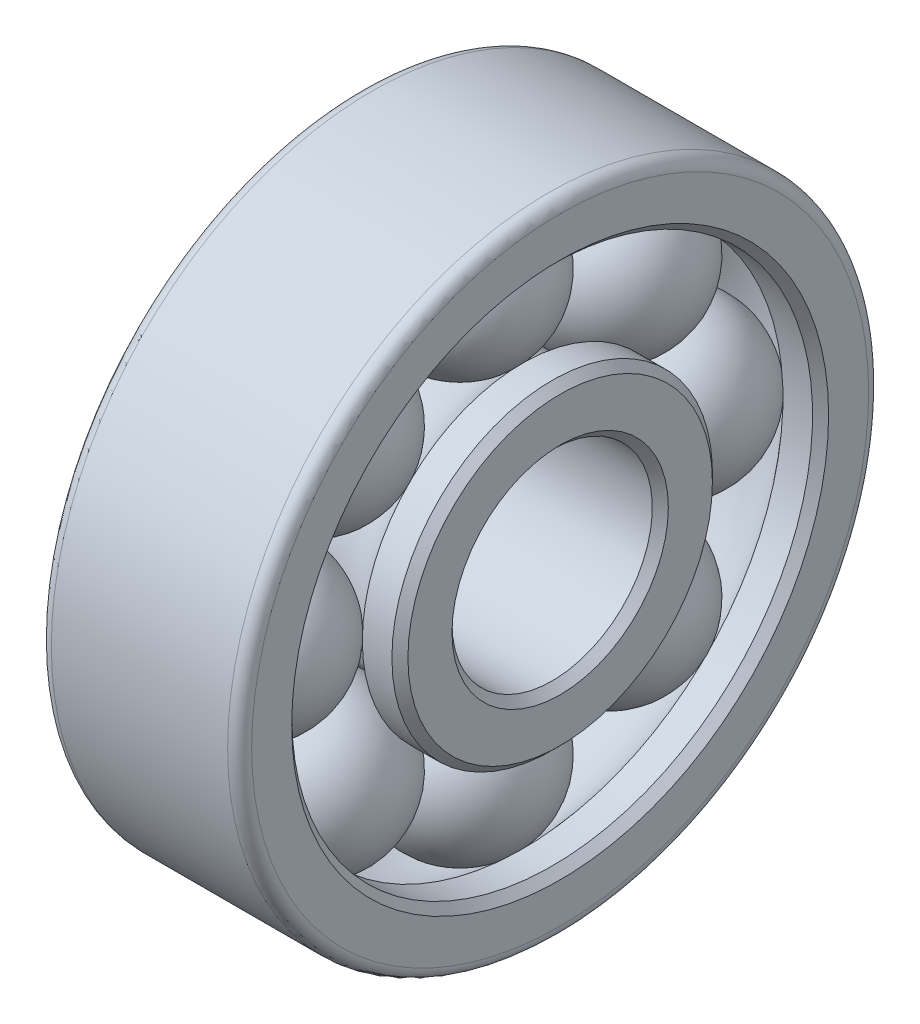
from build123d import *

# Parameters (mm, degrees)
PATTERN_CIRCULAR_5_COUNT = 8
FILLET_1_R               = 0.3
CHAMFER_1_SIZE           = 0.2
CHAMFER_2_SIZE           = 0.2


with BuildPart() as part:
    # Эскиз1 → Повернуть1 (revolve)
    with BuildSketch(Plane.XY):
        with BuildLine():
            Line((0, 0), (5, 0))
            Line((5, 0), (5, 1.5))
            Line((5, 1.5), (4.0612495, 1.5))
            ThreePointArc((4.0612495, 1.5), (2.5, 0.75), (0.9387505, 1.5))
            Line((0.9387505, 1.5), (0, 1.5))
            Line((0, 1.5), (0, 0))
        make_face()
        with BuildLine():
            Line((0, 4), (0.9387505, 4))
            ThreePointArc((0.9387505, 4), (2.5, 4.75), (4.0612495, 4))
            Line((4.0612495, 4), (5, 4))
            Line((5, 4), (5, 5.5))
            Line((5, 5.5), (0, 5.5))
            Line((0, 5.5), (0, 4))
        make_face()
    revolve(axis=Axis((-1.066901408, -2.5, 0), (1, 0, 0)))

    # Скругление1
    fillet_1_edges = [part.edges().sort_by_distance(p)[0] for p in [
        (0, -10.5, 0),
        (5, -10.5, 0),
    ]]
    fillet(fillet_1_edges, radius=FILLET_1_R)

    # Фаска1
    chamfer_1_edges = [part.edges().sort_by_distance(p)[0] for p in [
        (0, -6.5, 0),
        (5, -6.5, 0),
        (5, -5, 0),
        (0, -5, 0),
    ]]
    chamfer(chamfer_1_edges, length=CHAMFER_1_SIZE)

    # Фаска2
    chamfer_2_edges = [part.edges().sort_by_distance(p)[0] for p in [
        (5, -9, 0),
        (0, -9, 0),
    ]]
    chamfer(chamfer_2_edges, length=CHAMFER_2_SIZE)


with BuildPart() as body_2:
    # Эскиз2 → Повернуть2 (revolve)
    with BuildSketch(Plane.XY):
        with BuildLine():
            Line((2.5, 4.75), (2.5, 0.75))
            ThreePointArc((2.5, 0.75), (0.5, 2.75), (2.5, 4.75))
        make_face()
    revolve(axis=Axis((2.5, 4.75, 0), (0, -1, 0)))


with BuildPart() as pattern_circular_5_1:
    # Круговой массив5: pattern copy
    add(body_2.part.rotate(Axis((0, -2.5, 0), (1, 0, 0)), 1 * 360 / PATTERN_CIRCULAR_5_COUNT))


with BuildPart() as pattern_circular_5_2:
    # Круговой массив5: pattern copy
    add(body_2.part.rotate(Axis((0, -2.5, 0), (1, 0, 0)), 2 * 360 / PATTERN_CIRCULAR_5_COUNT))


with BuildPart() as pattern_circular_5_3:
    # Круговой массив5: pattern copy
    add(body_2.part.rotate(Axis((0, -2.5, 0), (1, 0, 0)), 3 * 360 / PATTERN_CIRCULAR_5_COUNT))


with BuildPart() as pattern_circular_5_4:
    # Круговой массив5: pattern copy
    add(body_2.part.rotate(Axis((0, -2.5, 0), (1, 0, 0)), 4 * 360 / PATTERN_CIRCULAR_5_COUNT))


with BuildPart() as pattern_circular_5_5:
    # Круговой массив5: pattern copy
    add(body_2.part.rotate(Axis((0, -2.5, 0), (1, 0, 0)), 5 * 360 / PATTERN_CIRCULAR_5_COUNT))


with BuildPart() as pattern_circular_5_6:
    # Круговой массив5: pattern copy
    add(body_2.part.rotate(Axis((0, -2.5, 0), (1, 0, 0)), 6 * 360 / PATTERN_CIRCULAR_5_COUNT))


with BuildPart() as pattern_circular_5_7:
    # Круговой массив5: pattern copy
    add(body_2.part.rotate(Axis((0, -2.5, 0), (1, 0, 0)), 7 * 360 / PATTERN_CIRCULAR_5_COUNT))


solid = Compound([part.part, body_2.part, pattern_circular_5_1.part, pattern_circular_5_2.part, pattern_circular_5_3.part, pattern_circular_5_4.part, pattern_circular_5_5.part, pattern_circular_5_6.part, pattern_circular_5_7.part])
